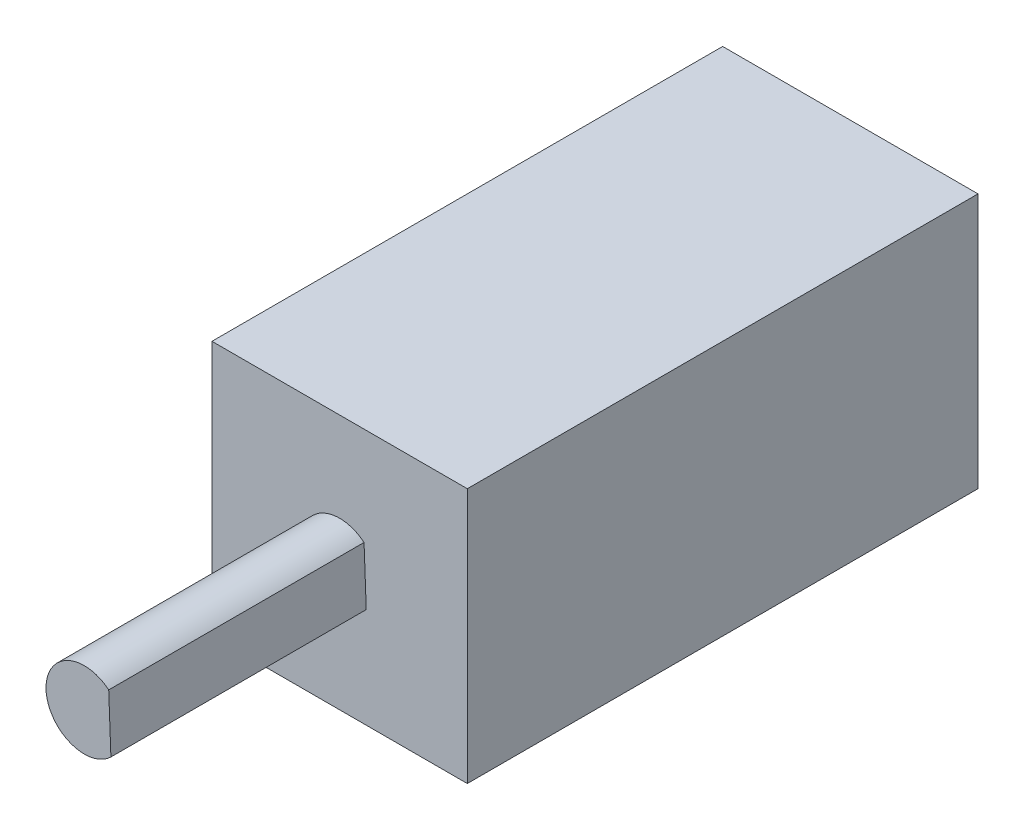
from build123d import *

# Parameters (mm, degrees)
SKETCH1_W           = 10
SKETCH1_H           = 10
BOSS_EXTRUDE1_DEPTH = 20
BOSS_EXTRUDE2_DEPTH = 10


with BuildPart() as part:
    # Sketch1 → Boss-Extrude1 (new body)
    with BuildSketch(Plane.XY):
        Rectangle(SKETCH1_W, SKETCH1_H)
    extrude(amount=BOSS_EXTRUDE1_DEPTH)

    # Sketch2 → Boss-Extrude2 (add)
    with BuildSketch(Plane.XY.offset(20)):
        with BuildLine():
            Line((0.956391162, 1.155558716), (1.0421378, -1.078864591))
            ThreePointArc((1.0421378, -1.078864591), (-1.498896721, -0.057520593), (0.956391162, 1.155558716))
        make_face()
    extrude(amount=BOSS_EXTRUDE2_DEPTH)


solid = part.part
